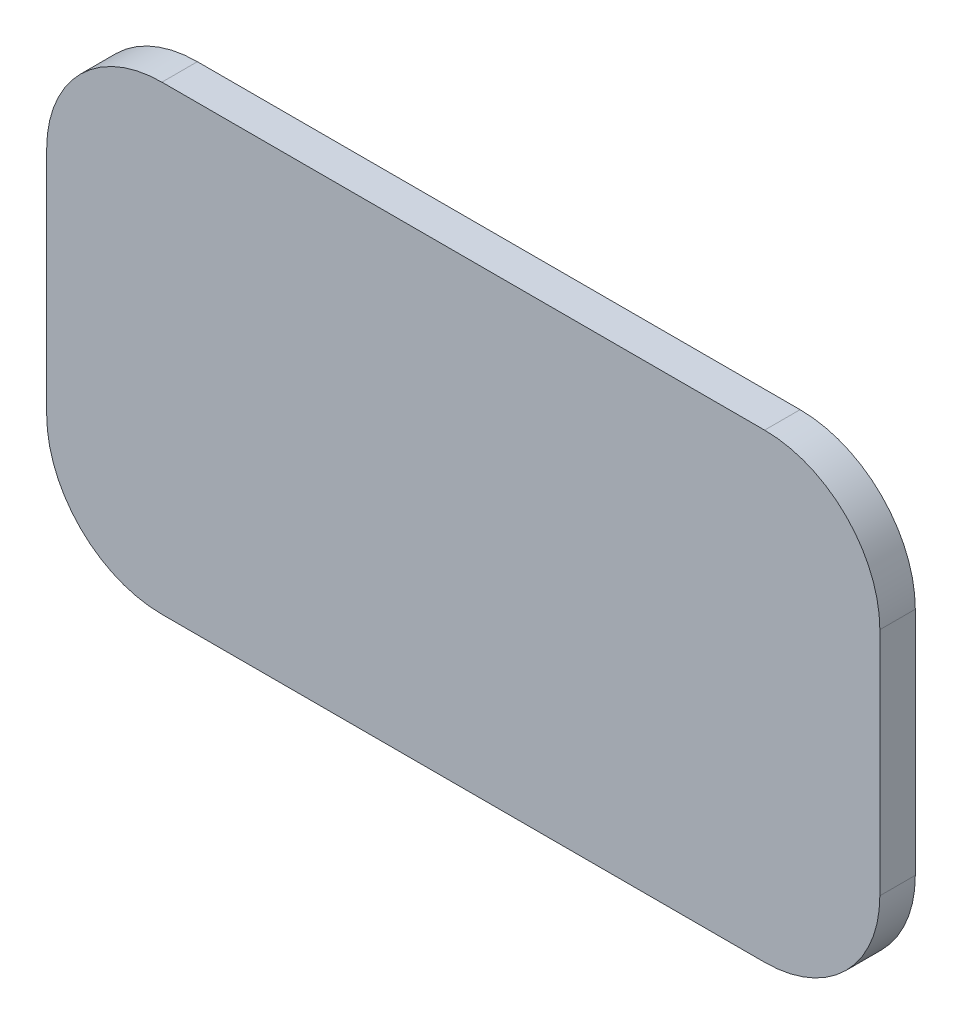
from build123d import *

# Parameters (mm, degrees)
EXTRUDE_1_DEPTH = 4


with BuildPart() as part:
    # Эскиз1 → Бобышка-Вытянуть1 (new body)
    with BuildSketch(Plane.XY):
        with BuildLine():
            Line((-34, 26), (34, 26))
            ThreePointArc((34, 26), (43.192388155, 22.192388155), (47, 13))
            Line((47, 13), (47, -13))
            ThreePointArc((47, -13), (43.192388155, -22.192388155), (34, -26))
            Line((34, -26), (-34, -26))
            ThreePointArc((-34, -26), (-43.192388155, -22.192388155), (-47, -13))
            Line((-47, -13), (-47, 13))
            ThreePointArc((-47, 13), (-43.192388155, 22.192388155), (-34, 26))
        make_face()
    extrude(amount=EXTRUDE_1_DEPTH)


solid = part.part
